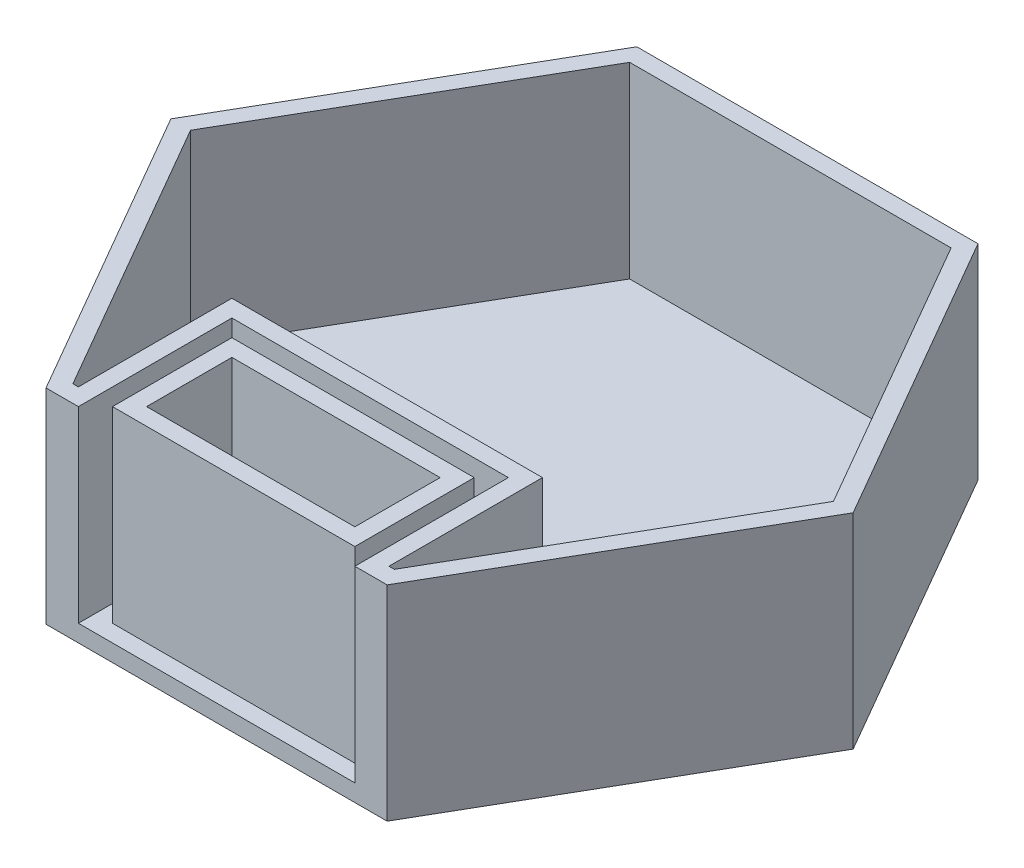
from build123d import *

# Parameters (mm, degrees)
BOSS_EXTRUDE1_DEPTH = 2.54
SKETCH3_W           = 36.089649417
SKETCH3_H           = 17.78
SKETCH3_W_2         = 31.009649417
SKETCH3_H_2         = 12.7
BOSS_EXTRUDE2_DEPTH = 30.48


with BuildPart() as part:
    # Sketch2 → Boss-Extrude1 (new body)
    with BuildSketch(Plane(origin=(0, 0, 0), x_dir=(1, 0, 0), z_dir=(0, 1, 0))):
        Polygon((76.2, 0), (101.6, 43.994090512), (76.2, 87.988181024), (25.4, 87.988181024), (0, 43.994090512), (25.4, 0), align=None)
    extrude(amount=BOSS_EXTRUDE1_DEPTH)

    # Sketch3 → Boss-Extrude2 (add)
    with BuildSketch(Plane(origin=(0, 0, 0), x_dir=(1, 0, 0), z_dir=(0, 1, 0))):
        with Locations((50.805939368, 11.43)):
            Rectangle(SKETCH3_W, SKETCH3_H)
        with Locations((50.805939368, 11.43)):
            Rectangle(SKETCH3_W_2, SKETCH3_H_2, mode=Mode.SUBTRACT)
        Polygon((30.221114659, 22.86), (30.221114659, 0), (25.4, 0), (0, 43.994090512), (25.4, 87.988181024), (76.2, 87.988181024), (101.6, 43.994090512), (76.2, 0), (71.390764076, 0), (71.390764076, 22.86), align=None)
        Polygon((73.930764076, 2.54), (74.733530316, 2.54), (98.667060633, 43.994090512), (74.733530316, 85.448181024), (26.866469684, 85.448181024), (2.932939367, 43.994090512), (26.866469684, 2.54), (27.681114659, 2.54), (27.681114659, 25.4), (73.930764076, 25.4), align=None, mode=Mode.SUBTRACT)
    extrude(amount=BOSS_EXTRUDE2_DEPTH)


solid = part.part
